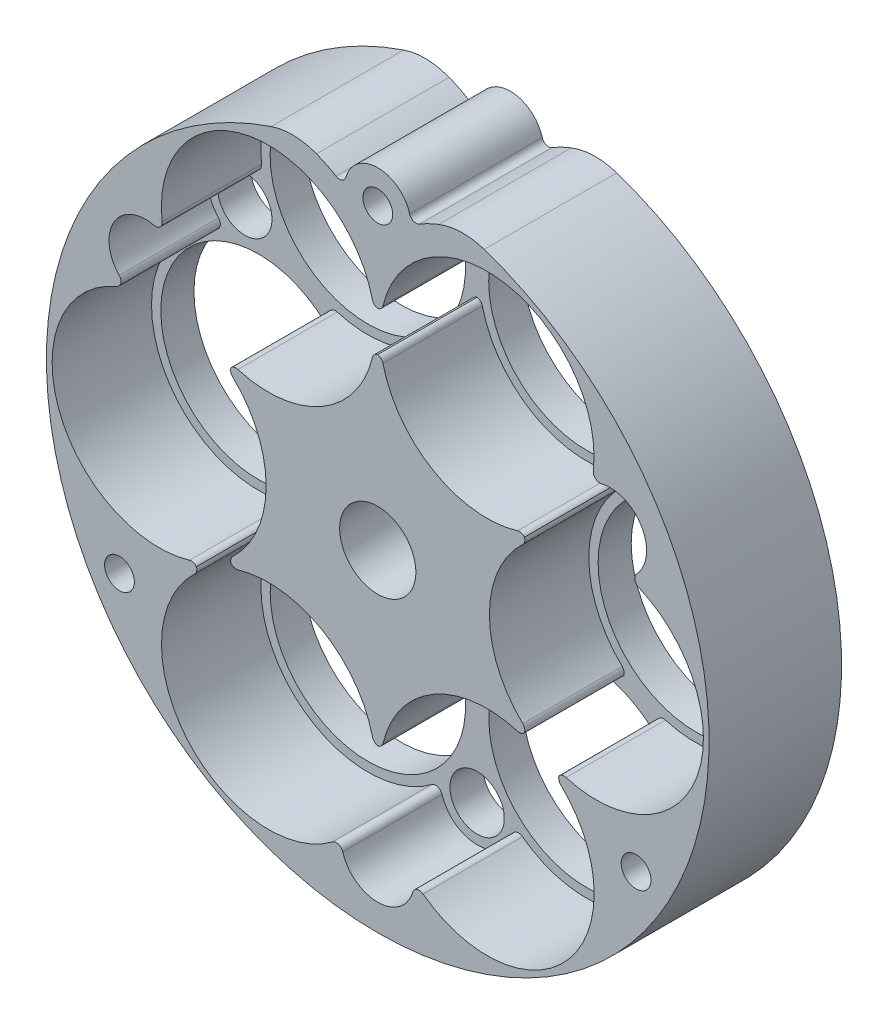
from build123d import *

# Parameters (mm, degrees)
EXTRUDE_1_DEPTH               = 20
CUT_EXTRUDE_1_DEPTH           = 15
EXTRUDE_2_DEPTH               = 15
HOLE_WIZARD_11_5_11_5_1_D     = 11.5
HOLE_WIZARD_11_5_11_5_1_DEPTH = 20
HOLE_WIZARD_4_5_4_5_1_D       = 4.5
HOLE_WIZARD_4_5_4_5_1_DEPTH   = 20
HOLE_WIZARD_8_2_8_2_1_D       = 8.2
HOLE_WIZARD_8_2_8_2_1_DEPTH   = 20
HOLE_WIZARD_M27_1_D           = 29.5
HOLE_WIZARD_M27_1_DEPTH       = 20
FILLET_1_R                    = 10


with BuildPart() as part:
    # 草图1 → 凸台-拉伸1 (new body)
    with BuildSketch(Plane(origin=(0, 0, 0), x_dir=(-1, 0, 0), z_dir=(0, 0, -1))):
        with BuildLine():
            ThreePointArc((-163.044825793, 48.268338691), (-150.013943269, -49.999998056), (-136.9282555, 48.261055684))
            ThreePointArc((-136.9282555, 48.261055684), (-140.436485638, 47.315672166), (-143.715786974, 45.751187764))
            ThreePointArc((-143.715786974, 45.751187764), (-144.598832064, 45.682763471), (-145.189860946, 46.34241139))
            ThreePointArc((-145.189860946, 46.34241139), (-149.9980945, 49.999993293), (-154.818283841, 46.35818193))
            ThreePointArc((-154.818283841, 46.35818193), (-155.409600478, 45.701218741), (-156.290828184, 45.76972954))
            ThreePointArc((-156.290828184, 45.76972954), (-159.554442065, 47.325525228), (-163.044825793, 48.268338691))
        make_face()
    extrude(amount=-EXTRUDE_1_DEPTH)

    # 草图2 → 切除-拉伸1 (cut)
    with BuildSketch(Plane.XY.offset(20)):
        with BuildLine():
            ThreePointArc((182.530473967, 26.658794029), (169.344288449, 44.464391856), (150.792813346, 32.350037808))
            ThreePointArc((150.792813346, 32.350037808), (150.506114031, 31.856143154), (149.995856029, 31.599695892))
            ThreePointArc((149.995856029, 31.599695892), (149.485428939, 31.855806439), (149.198403823, 32.349511827))
            ThreePointArc((149.198403823, 32.349511827), (130.657581348, 44.454967541), (117.460046658, 26.674944082))
            ThreePointArc((117.460046658, 26.674944082), (117.13046307, 25.810318318), (116.2327011, 25.586205625))
            ThreePointArc((116.2327011, 25.586205625), (110.175484721, 22.978350815), (110.975201971, 16.432265779))
            ThreePointArc((110.975201971, 16.432265779), (111.233397945, 15.540844642), (110.647570153, 14.821051199))
            ThreePointArc((110.647570153, 14.821051199), (101.822353243, -5.506280624), (121.597754537, -15.507199392))
            ThreePointArc((121.597754537, -15.507199392), (122.167866534, -15.507879551), (122.644955628, -15.819991947))
            ThreePointArc((122.644955628, -15.819991947), (122.677083904, -16.389198347), (122.392942981, -16.883457477))
            ThreePointArc((122.392942981, -16.883457477), (121.168678782, -38.996245439), (143.168797451, -41.539666912))
            ThreePointArc((143.168797451, -41.539666912), (144.082377122, -41.39278179), (144.725345392, -42.058210116))
            ThreePointArc((144.725345392, -42.058210116), (150.012422097, -45.999985972), (155.281639409, -42.034367999))
            ThreePointArc((155.281639409, -42.034367999), (155.924534771, -41.365053158), (156.840808075, -41.512498187))
            ThreePointArc((156.840808075, -41.512498187), (178.860797944, -38.987667291), (177.623107818, -16.85798478))
            ThreePointArc((177.623107818, -16.85798478), (177.338551357, -16.365073167), (177.369025987, -15.796737408))
            ThreePointArc((177.369025987, -15.796737408), (177.845776872, -15.485863106), (178.414928942, -15.485464907))
            ThreePointArc((178.414928942, -15.485464907), (198.1856076, -5.497255844), (189.390008085, 14.832069871))
            ThreePointArc((189.390008085, 14.832069871), (188.806012002, 15.549810513), (189.060805702, 16.439351532))
            ThreePointArc((189.060805702, 16.439351532), (189.830945377, 22.988982198), (183.762010815, 25.569449262))
            ThreePointArc((183.762010815, 25.569449262), (182.860919479, 25.791555557), (182.530473967, 26.658794029))
        make_face()
    extrude(amount=-CUT_EXTRUDE_1_DEPTH, mode=Mode.SUBTRACT)

    # 草图3 → 凸台-拉伸2 (add)
    with BuildSketch(Plane.XY.offset(5)):
        with BuildLine():
            ThreePointArc((150.806742296, -24.817251573), (150.522146149, -25.310140695), (150.014715092, -25.56791652))
            ThreePointArc((150.014715092, -25.56791652), (149.507114069, -25.310475545), (149.222192785, -24.817774301))
            ThreePointArc((149.222192785, -24.817774301), (141.584673617, -14.598117133), (128.913467977, -13.110286731))
            ThreePointArc((128.913467977, -13.110286731), (128.345273464, -13.110918369), (127.868454338, -12.801905545))
            ThreePointArc((127.868454338, -12.801905545), (127.838876563, -12.234481049), (128.123196321, -11.742538289))
            ThreePointArc((128.123196321, -11.742538289), (133.162564653, -0.011170953), (128.107804336, 11.71357258))
            ThreePointArc((128.107804336, 11.71357258), (127.823073861, 12.2041736), (127.851011875, 12.770724808))
            ThreePointArc((127.851011875, 12.770724808), (128.32748764, 13.078509879), (128.894726547, 13.077600818))
            ThreePointArc((128.894726547, 13.077600818), (141.579615252, 14.573425047), (149.210722651, 24.815987784))
            ThreePointArc((149.210722651, 24.815987784), (149.493229963, 25.307871928), (149.997846175, 25.566952748))
            ThreePointArc((149.997846175, 25.566952748), (150.502633213, 25.30820492), (150.785465, 24.816507277))
            ThreePointArc((150.785465, 24.816507277), (158.418767714, 14.58161384), (171.099107848, 13.088520381))
            ThreePointArc((171.099107848, 13.088520381), (171.667301632, 13.089152517), (172.144120652, 12.78014087))
            ThreePointArc((172.144120652, 12.78014087), (172.173697461, 12.212717053), (171.889377635, 11.720775173))
            ThreePointArc((171.889377635, 11.720775173), (166.85, -5.6959e-05), (171.889460311, -11.720853545))
            ThreePointArc((171.889460311, -11.720853545), (172.174016773, -12.213765158), (172.143542142, -12.782100917))
            ThreePointArc((172.143542142, -12.782100917), (171.666791258, -13.092975219), (171.097639187, -13.093373418))
            ThreePointArc((171.097639187, -13.093373418), (158.432956354, -14.595191678), (150.806742296, -24.817251573))
        make_face()
    extrude(amount=EXTRUDE_2_DEPTH)

    # Ø11.5 (11.5) 直径孔1
    with Locations(Plane(origin=(0, 0, 0), x_dir=(-1, 0, 0), z_dir=(0, 0, -1))):
        with Locations((-150, 0)):
            Hole(HOLE_WIZARD_11_5_11_5_1_D / 2, depth=HOLE_WIZARD_11_5_11_5_1_DEPTH)

    # Ø4.5 (4.5) 直径孔1
    with Locations(Plane(origin=(0, 0, 0), x_dir=(-1, 0, 0), z_dir=(0, 0, -1))):
        with Locations((-150.006284065, 45), (-111.025714797, -22.516326479), (-188.986853332, -22.516326479)):
            Hole(HOLE_WIZARD_4_5_4_5_1_D / 2, depth=HOLE_WIZARD_4_5_4_5_1_DEPTH)

    # Ø8.2 (8.2) 直径孔1
    with Locations(Plane(origin=(0, 0, 0), x_dir=(-1, 0, 0), z_dir=(0, 0, -1))):
        with Locations((-150, -40.5), (-114.944823341, 20.23911568), (-185.074028853, 20.228231361)):
            Hole(HOLE_WIZARD_8_2_8_2_1_D / 2, depth=HOLE_WIZARD_8_2_8_2_1_DEPTH)

    # M27 间隙孔1
    with Locations(Plane(origin=(0, 0, 0), x_dir=(-1, 0, 0), z_dir=(0, 0, -1))):
        with Locations((-183, 0), (-166.51256813, -28.578838325), (-133.518852195, -28.589722645), (-166.493715935, 28.567954005), (-117.01256813, -0.021768639), (-133.5, 28.557069686)):
            Hole(HOLE_WIZARD_M27_1_D / 2, depth=HOLE_WIZARD_M27_1_DEPTH)

    # 圆角1
    fillet_1_edges = [part.edges().sort_by_distance(p)[0] for p in [
        (136.9282555, 48.261055684, 10),
        (163.044825793, 48.268338691, 10),
    ]]
    fillet(fillet_1_edges, radius=FILLET_1_R)


solid = part.part
